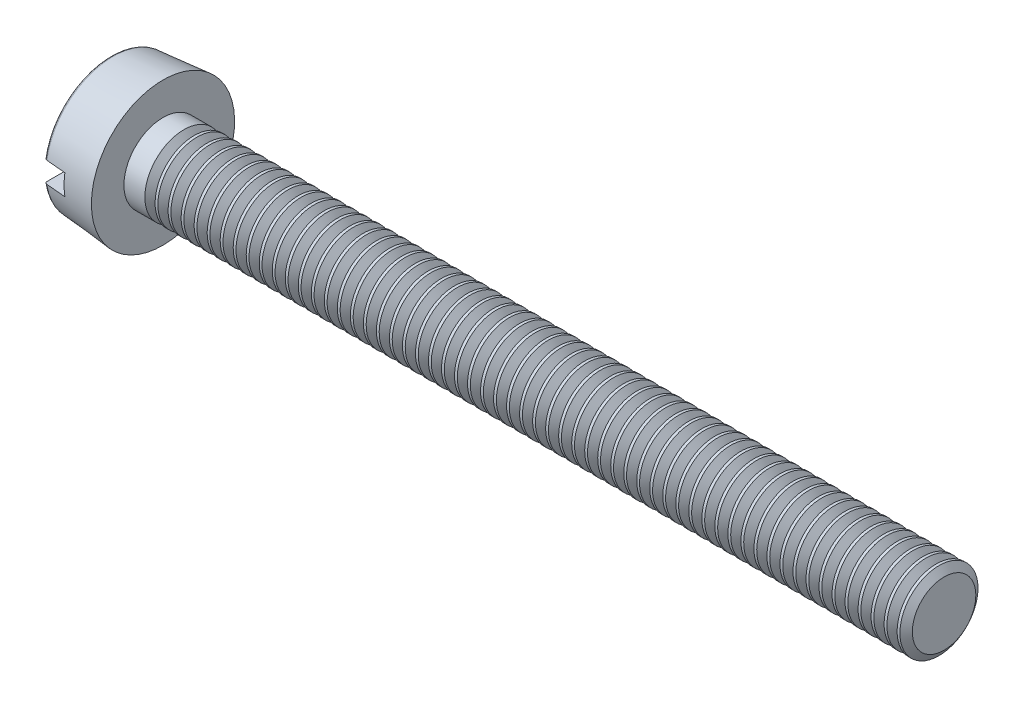
from build123d import *

# Parameters (mm, degrees)
FILLET2_R       = 0.1
SKETCH2_W       = 5.5
SKETCH2_H       = 0.8
SLOT_DEPTH      = 0.85
THDSCHPAT_COUNT = 59
THDSCHPAT_PITCH = 0.5


with BuildPart() as part:
    # BodySke → Base-Revolve (revolve)
    with BuildSketch(Plane.XY):
        Polygon((2, 1.5), (2, 2.75), (0, 2.575022673), (0, 0), (32, 0), (32, 1.5), align=None)
    revolve(axis=Axis((-25.4, 0, 0), (1, 0, 0)))

    # Fillet2
    fillet2_edges = [part.edges().sort_by_distance(p)[0] for p in [
        (0, -2.575022673, 0),
    ]]
    fillet(fillet2_edges, radius=FILLET2_R)

    # Sketch2 → Slot (cut)
    with BuildSketch(Plane(origin=(0, 0, 0), x_dir=(0, 0, -1), z_dir=(1, 0, 0))):
        Rectangle(SKETCH2_W, SKETCH2_H)
    extrude(amount=SLOT_DEPTH, mode=Mode.SUBTRACT)

    # ThdSchSke → ThreadSchematic (revolve, cut)
    with BuildSketch(Plane.XY):
        Polygon((3, -1.2195), (2.803591786, -1.5), (2.803591786, -1.875), (3.196408214, -1.875), (3.196408214, -1.5), align=None)
    threadschematic = revolve(axis=Axis((-3.175, 0, 0), (1, 0, 0)), mode=Mode.SUBTRACT)

    # ThdSchPat: ThreadSchematic ×59
    with Locations(*[(i * THDSCHPAT_PITCH, 0, 0) for i in range(1, THDSCHPAT_COUNT)]):
        add(threadschematic, mode=Mode.SUBTRACT)


solid = part.part
